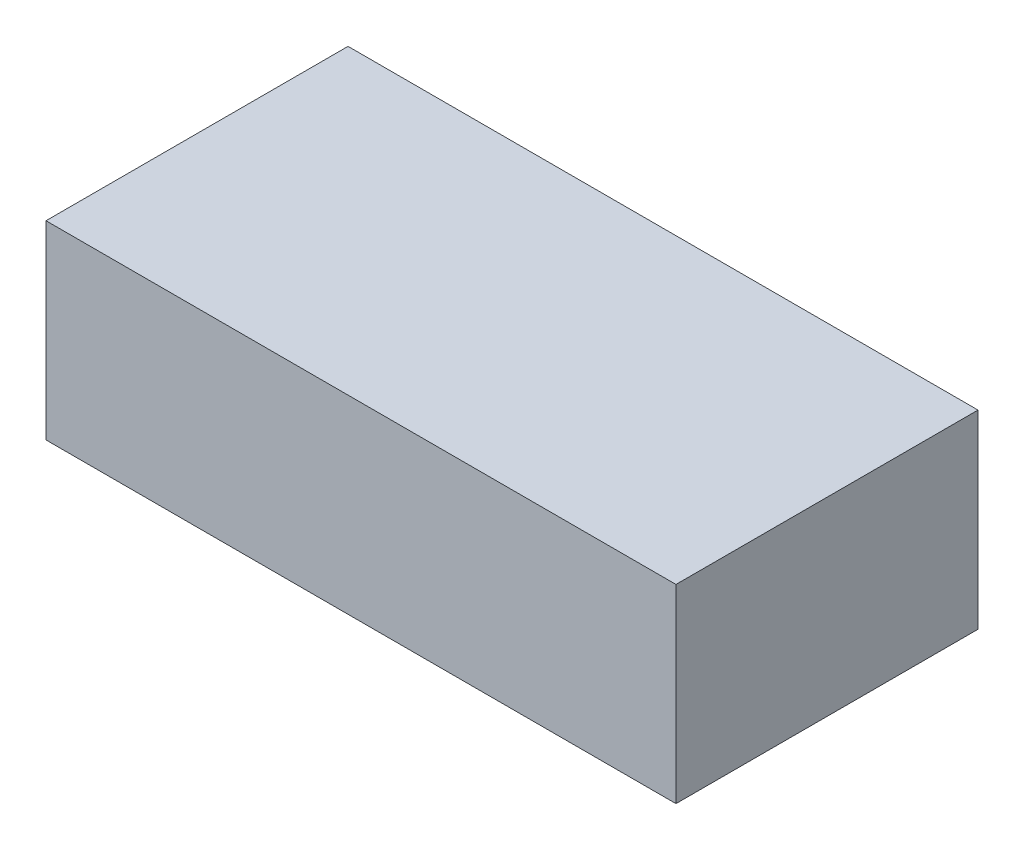
from build123d import *

# Parameters (mm, degrees)
SKETCH1_W           = 73
SKETCH1_H           = 35
BOSS_EXTRUDE1_DEPTH = 22


with BuildPart() as part:
    # Sketch1 → Boss-Extrude1 (new body)
    with BuildSketch(Plane(origin=(0, 0, 0), x_dir=(1, 0, 0), z_dir=(0, 1, 0))):
        Rectangle(SKETCH1_W, SKETCH1_H)
    extrude(amount=BOSS_EXTRUDE1_DEPTH)


solid = part.part
